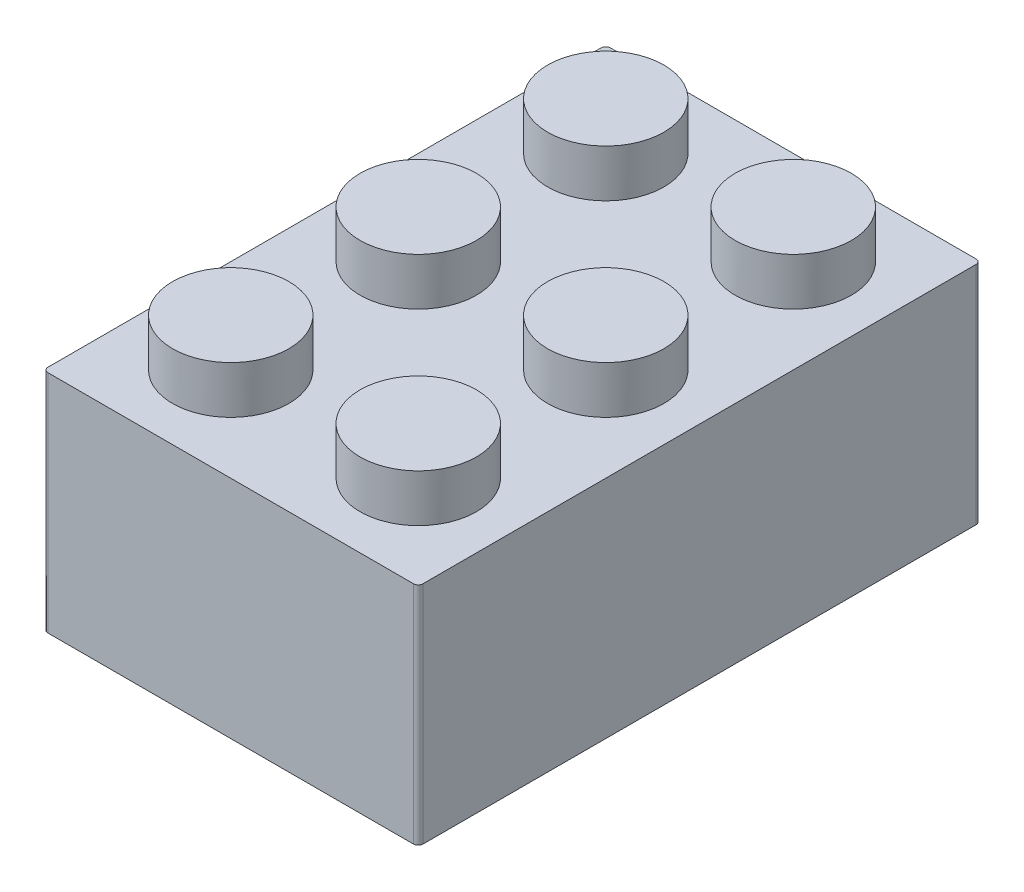
from build123d import *

# Parameters (mm, degrees)
SKETCH1_W           = 15.8
SKETCH1_H           = 23.7
BOSS_EXTRUDE1_DEPTH = 4.75
SKETCH2_R           = 2.45
BOSS_EXTRUDE2_DEPTH = 2
SKETCH4_W           = 12.9
SKETCH4_H           = 20.8
CUT_EXTRUDE1_DEPTH  = 4
SKETCH5_R           = 3.2
SKETCH5_R_2         = 2.4
BOSS_EXTRUDE3_DEPTH = 4
FILLET1_R           = 0.2


with BuildPart() as part:
    # Sketch1 → Boss-Extrude1 (new body, symmetric)
    with BuildSketch(Plane(origin=(0, 0, 0), x_dir=(1, 0, 0), z_dir=(0, 1, 0))):
        with Locations((7.9, 11.85)):
            Rectangle(SKETCH1_W, SKETCH1_H)
    extrude(amount=BOSS_EXTRUDE1_DEPTH, both=True)

    # Sketch2 → Boss-Extrude2 (add)
    with BuildSketch(Plane(origin=(0, 4.75, 0), x_dir=(1, 0, 0), z_dir=(0, 1, 0))):
        with Locations((3.95, 3.95)):
            Circle(SKETCH2_R)
        with Locations((11.85, 3.95)):
            Circle(SKETCH2_R)
        with Locations((11.85, 11.85)):
            Circle(SKETCH2_R)
        with Locations((3.95, 11.85)):
            Circle(SKETCH2_R)
        with Locations((3.95, 19.75)):
            Circle(SKETCH2_R)
        with Locations((11.85, 19.75)):
            Circle(SKETCH2_R)
    extrude(amount=BOSS_EXTRUDE2_DEPTH)

    # Sketch4 → Cut-Extrude1 (cut)
    with BuildSketch(Plane.XZ.offset(4.75)):
        with Locations((7.9, -11.85)):
            Rectangle(SKETCH4_W, SKETCH4_H)
    extrude(amount=-CUT_EXTRUDE1_DEPTH, mode=Mode.SUBTRACT)

    # Sketch5 → Boss-Extrude3 (add)
    with BuildSketch(Plane.XZ.offset(0.75)):
        with Locations((7.9, -15.8)):
            Circle(SKETCH5_R)
        with Locations((7.9, -15.8)):
            Circle(SKETCH5_R_2, mode=Mode.SUBTRACT)
        with Locations((7.9, -7.9)):
            Circle(SKETCH5_R)
        with Locations((7.9, -7.9)):
            Circle(SKETCH5_R_2, mode=Mode.SUBTRACT)
    extrude(amount=BOSS_EXTRUDE3_DEPTH)

    # Fillet1
    fillet1_edges = [part.edges().sort_by_distance(p)[0] for p in [
        (0, 0, -23.7),
        (15.8, 0, -23.7),
        (15.8, 0, 0),
        (0, 0, 0),
    ]]
    fillet(fillet1_edges, radius=FILLET1_R)


solid = part.part
